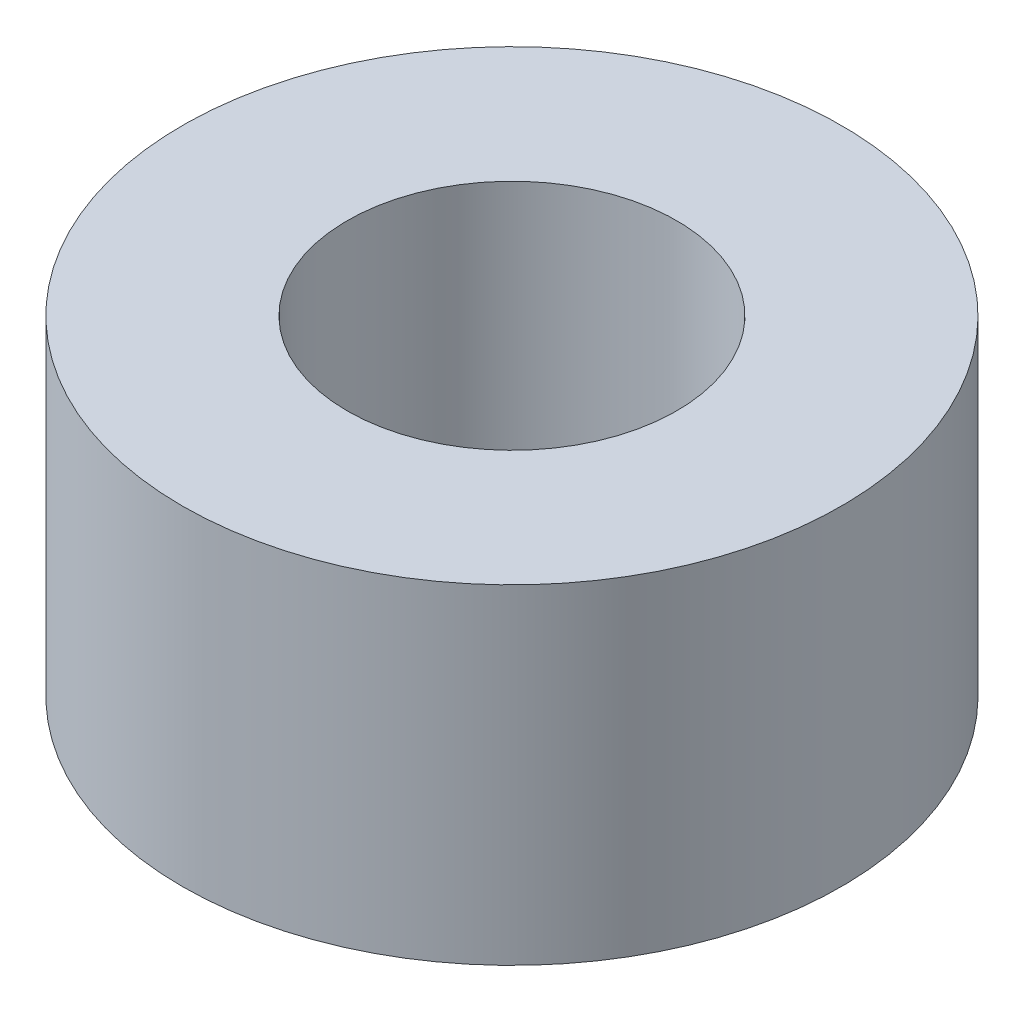
from build123d import *

# Parameters (mm, degrees)
SKETCH1_R           = 6.35
SKETCH1_R_2         = 3.175
BOSS_EXTRUDE1_DEPTH = 3.175


with BuildPart() as part:
    # Sketch1 → Boss-Extrude1 (new, symmetric)
    with BuildSketch(Plane(origin=(0, 0, 0), x_dir=(1, 0, 0), z_dir=(0, 1, 0))):
        Circle(SKETCH1_R)
        Circle(SKETCH1_R_2, mode=Mode.SUBTRACT)
    extrude(amount=BOSS_EXTRUDE1_DEPTH, both=True)


solid = part.part
